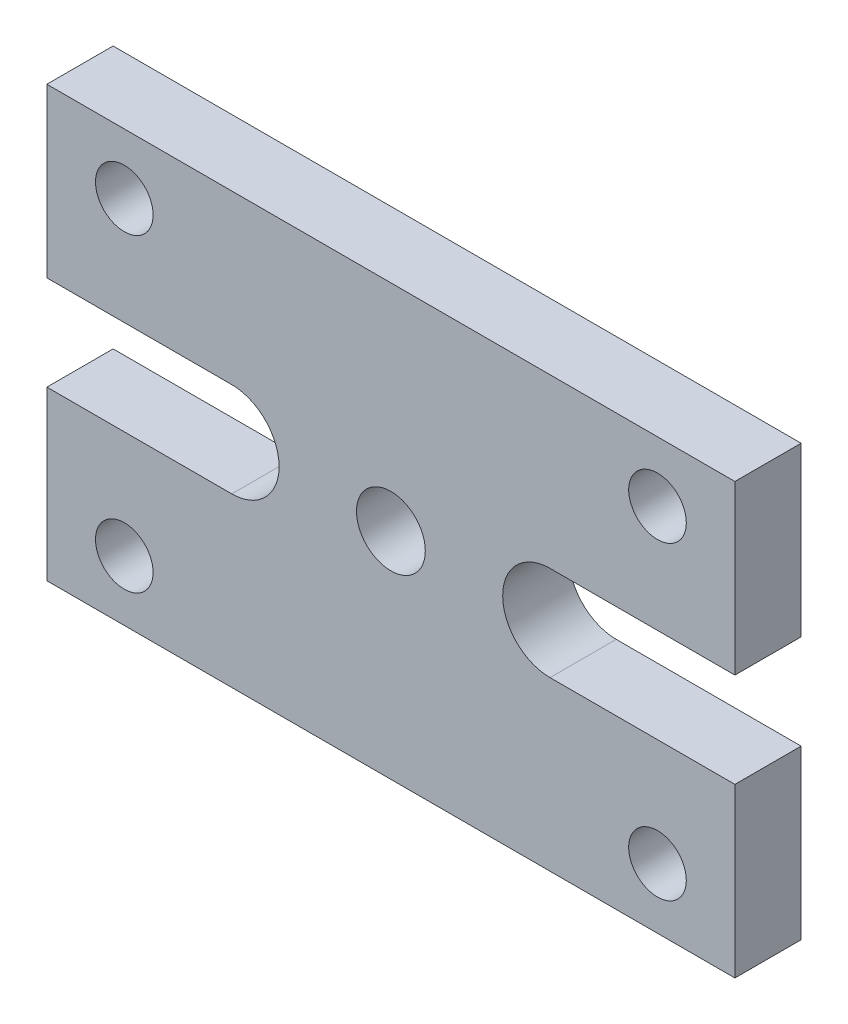
from build123d import *

# Parameters (mm, degrees)
BOSS_EXTRUDE1_DEPTH        = 7.7
F_6_7_6_7_DIAMETER_HOLE1_D = 6.7
F_8_0_8_DIAMETER_HOLE1_D   = 8


with BuildPart() as part:
    # Sketch1 → Boss-Extrude1 (new body)
    with BuildSketch(Plane.XY):
        with BuildLine():
            Line((-40, 25), (40, 25))
            Line((40, 25), (40, 5.5))
            Line((40, 5.5), (18.5, 5.5))
            ThreePointArc((18.5, 5.5), (13, 0), (18.5, -5.5))
            Line((18.5, -5.5), (40, -5.5))
            Line((40, -5.5), (40, -25))
            Line((40, -25), (-40, -25))
            Line((-40, -25), (-40, -5.5))
            Line((-40, -5.5), (-18.5, -5.5))
            ThreePointArc((-18.5, -5.5), (-13, 0), (-18.5, 5.5))
            Line((-18.5, 5.5), (-40, 5.5))
            Line((-40, 5.5), (-40, 25))
        make_face()
    extrude(amount=BOSS_EXTRUDE1_DEPTH)

    # Ø6.7 (6.7) Diameter Hole1 (through all)
    with Locations(Plane.XY.offset(7.7)):
        with Locations((31, 18), (-31, 18), (-31, -18), (31, -18)):
            Hole(F_6_7_6_7_DIAMETER_HOLE1_D / 2)

    # Ø8.0 (8) Diameter Hole1 (through all)
    with Locations(Plane.XY.offset(7.7)):
        with Locations((0, 0)):
            Hole(F_8_0_8_DIAMETER_HOLE1_D / 2)


solid = part.part
